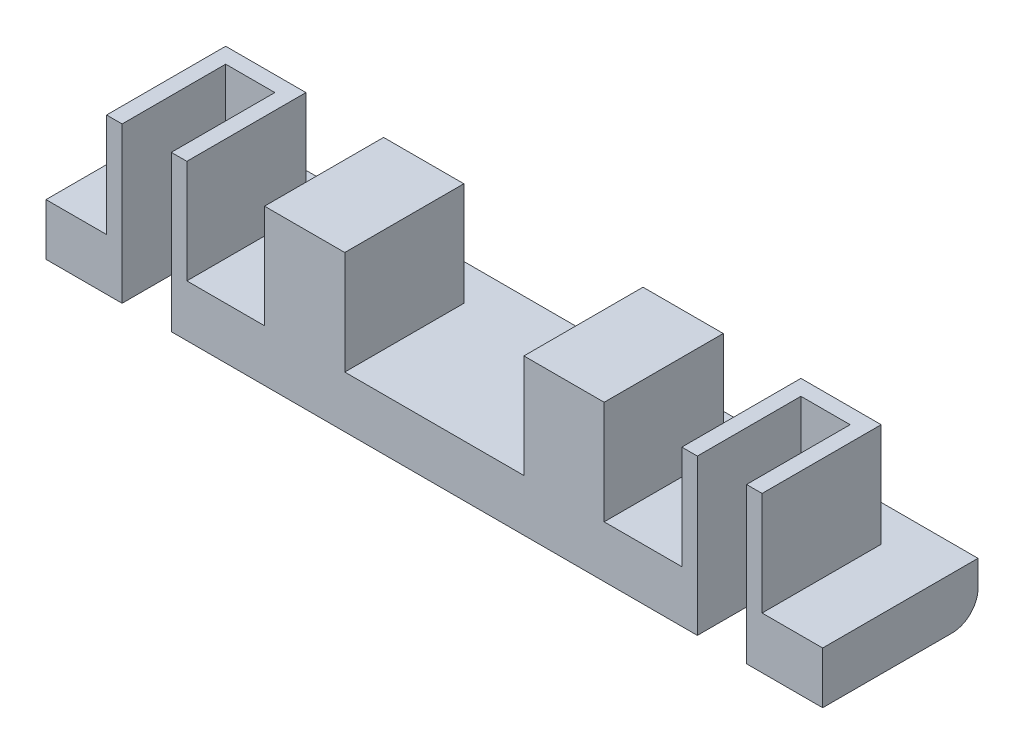
from build123d import *

# Parameters (mm, degrees)
SKETCH1_W           = 150
SKETCH1_H           = 30
BOSS_EXTRUDE1_DEPTH = 10
SKETCH2_W           = 9.5
SKETCH2_H           = 20
CUT_EXTRUDE1_DEPTH  = 10
SKETCH2_3_W         = 15.5
SKETCH2_3_H         = 23
BOSS_EXTRUDE2_DEPTH = 20
FILLET1_R           = 5


with BuildPart() as part:
    # Sketch1 → Boss-Extrude1 (new body)
    with BuildSketch(Plane(origin=(0, 0, 0), x_dir=(1, 0, 0), z_dir=(0, 1, 0))):
        Rectangle(SKETCH1_W, SKETCH1_H)
    extrude(amount=BOSS_EXTRUDE1_DEPTH)

    # Sketch2 → Cut-Extrude1 (cut)
    with BuildSketch(Plane(origin=(0, 10, 0), x_dir=(1, 0, 0), z_dir=(0, 1, 0))):
        with Locations((-55.55, -5)):
            Rectangle(SKETCH2_W, SKETCH2_H)
        with Locations((55.55, -5)):
            Rectangle(SKETCH2_W, SKETCH2_H)
    extrude(amount=-CUT_EXTRUDE1_DEPTH, mode=Mode.SUBTRACT)

    # Sketch2_3 → Boss-Extrude2 (add)
    with BuildSketch(Plane(origin=(0, 10, 0), x_dir=(1, 0, 0), z_dir=(0, 1, 0))):
        Polygon((-63.3, 8), (-63.3, -15), (-60.3, -15), (-60.3, 5), (-50.8, 5), (-50.8, -15), (-47.8, -15), (-47.8, 8), align=None)
        Polygon((47.8, 8), (47.8, -15), (50.8, -15), (50.8, 5), (60.3, 5), (60.3, -15), (63.3, -15), (63.3, 8), align=None)
        with Locations((25.05, -3.5)):
            Rectangle(SKETCH2_3_W, SKETCH2_3_H)
        with Locations((-25.05, -3.5)):
            Rectangle(SKETCH2_3_W, SKETCH2_3_H)
    extrude(amount=BOSS_EXTRUDE2_DEPTH)

    # Fillet1
    fillet1_edges = [part.edges().sort_by_distance(p)[0] for p in [
        (0, 0, -15),
    ]]
    fillet(fillet1_edges, radius=FILLET1_R)


solid = part.part
